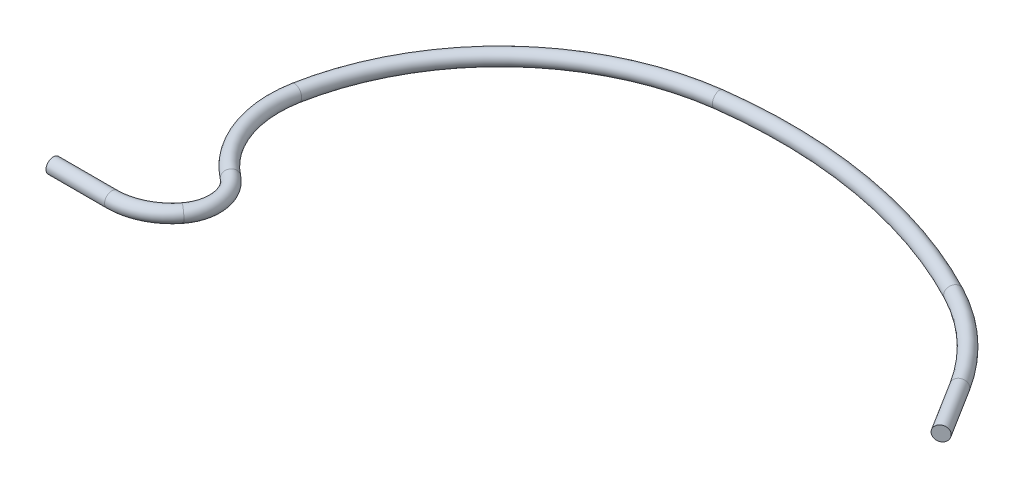
from build123d import *

# Parameters (mm, degrees)
SKETCH_1_R = 2.5


with BuildPart() as part:
    # Wire 2: sweep along a path in SWireLine
    with BuildLine(Plane(origin=(0, 0, 0), x_dir=(1, 0, 0), z_dir=(0, 1, 0))) as wire_2_path:
        Line((0, 0), (20, 0))
        ThreePointArc((20, 0), (29.011943233, 2.091873975), (36.180904523, 7.939698492))
        ThreePointArc((36.180904523, 7.939698492), (38.86499133, 17.80029249), (33.79043443, 26.670721354))
        ThreePointArc((33.79043443, 26.670721354), (21.82641851, 42.786838621), (20, 62.775112886))
        ThreePointArc((20, 62.775112886), (45.584965842, 109.96543175), (94.022959085, 133.101496287))
        ThreePointArc((94.022959085, 133.101496287), (144.087790428, 131.993629879), (191.475888414, 115.804656017))
        ThreePointArc((191.475888414, 115.804656017), (207.587532964, 104.423854927), (220.163330814, 89.226584382))
        Line((220.163330814, 89.226584382), (230.770585075, 72.271167635))
    # 草图1 → Wire 2 (sweep)
    with BuildSketch(Plane(origin=(0, 0, 0), x_dir=(0, 0, -1), z_dir=(1, 0, 0))):
        Circle(SKETCH_1_R)
    sweep(path=wire_2_path.line)


solid = part.part
